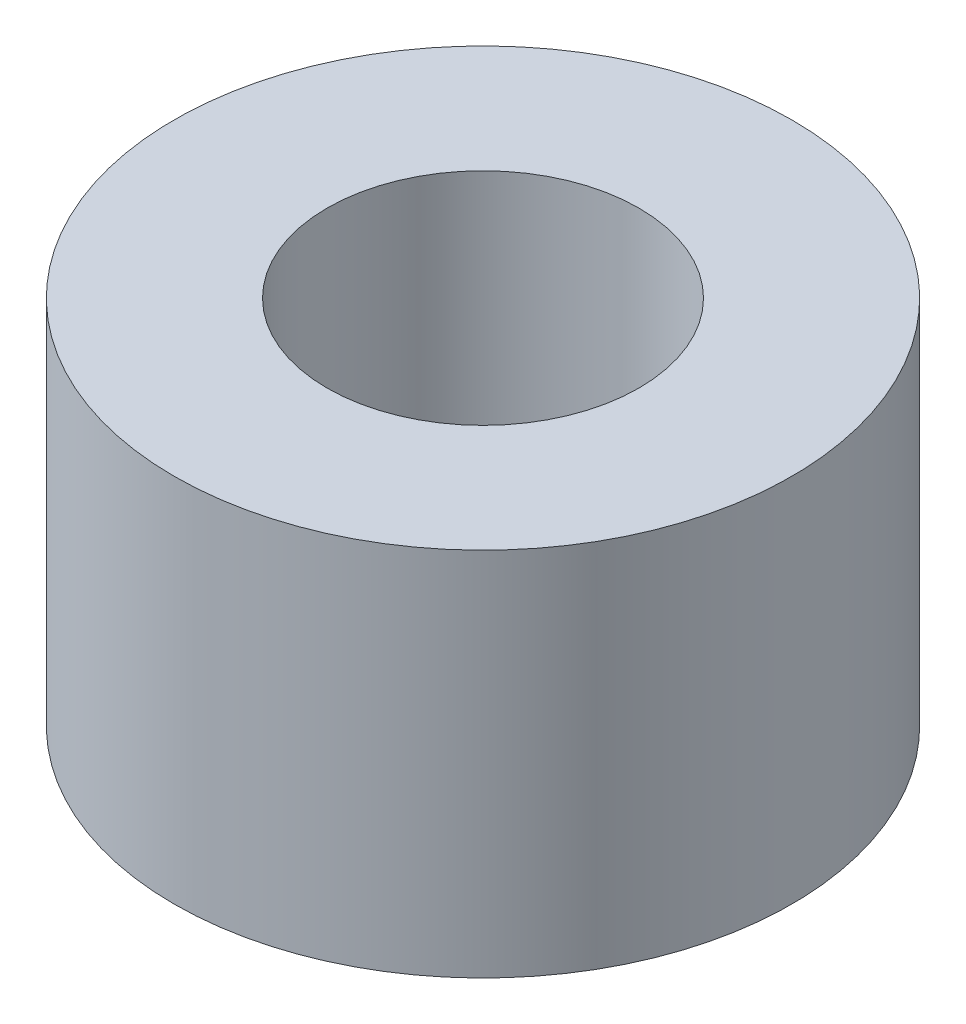
from build123d import *

# Parameters (mm, degrees)
SKETCH1_R           = 5
SKETCH1_R_2         = 2.525
BOSS_EXTRUDE1_DEPTH = 6


with BuildPart() as part:
    # Sketch1 → Boss-Extrude1 (new body)
    with BuildSketch(Plane(origin=(0, 0, 0), x_dir=(1, 0, 0), z_dir=(0, 1, 0))):
        Circle(SKETCH1_R)
        Circle(SKETCH1_R_2, mode=Mode.SUBTRACT)
    extrude(amount=BOSS_EXTRUDE1_DEPTH)


solid = part.part
